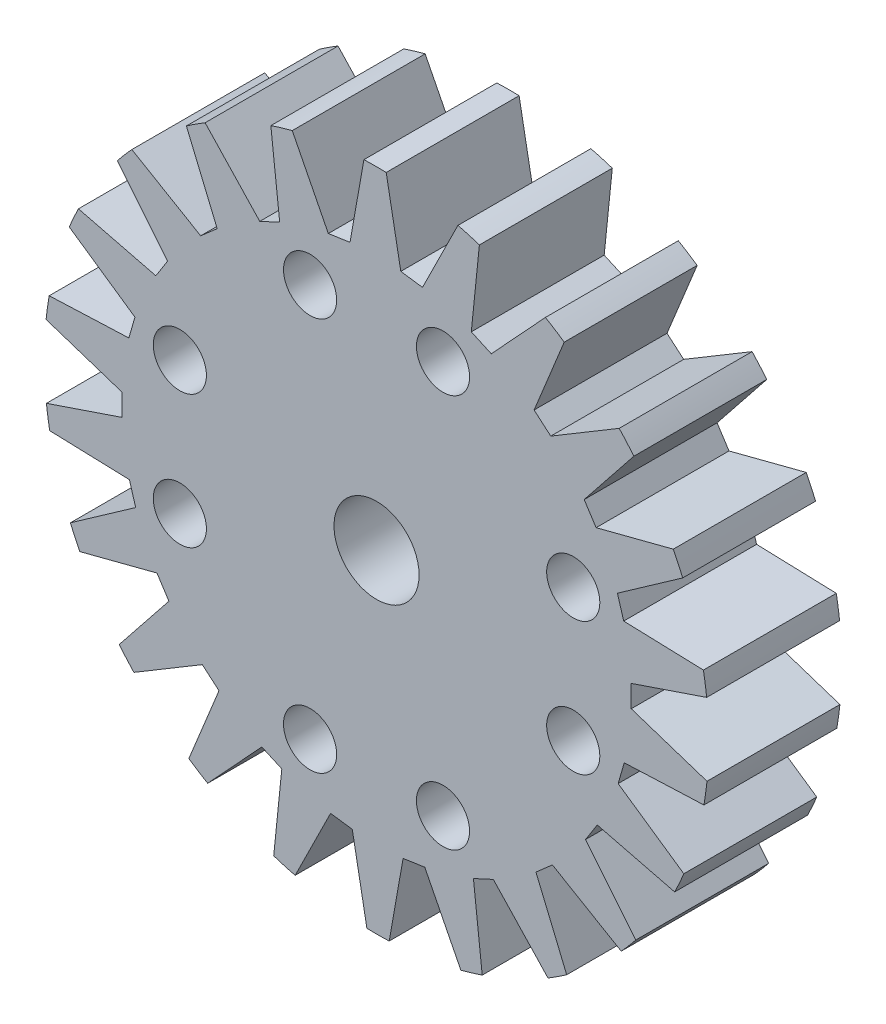
from build123d import *

# Parameters (mm, degrees)
SKETCH1_R           = 12.5
SKETCH1_R_2         = 1.6
SKETCH1_R_3         = 1
BOSS_EXTRUDE1_DEPTH = 5
CUT_EXTRUDE1_DEPTH  = 6
CIRPATTERN1_COUNT   = 22


with BuildPart() as part:
    # Sketch1 → Boss-Extrude1 (new body)
    with BuildSketch(Plane.XY):
        Circle(SKETCH1_R)
        Circle(SKETCH1_R_2, mode=Mode.SUBTRACT)
        with Locations((-2.5, 7.4)):
            Circle(SKETCH1_R_3, mode=Mode.SUBTRACT)
        with Locations((2.5, 7.4)):
            Circle(SKETCH1_R_3, mode=Mode.SUBTRACT)
        with Locations((2.5, -7.4)):
            Circle(SKETCH1_R_3, mode=Mode.SUBTRACT)
        with Locations((-2.5, -7.4)):
            Circle(SKETCH1_R_3, mode=Mode.SUBTRACT)
        with Locations((7.4, -2.5)):
            Circle(SKETCH1_R_3, mode=Mode.SUBTRACT)
        with Locations((7.4, 2.5)):
            Circle(SKETCH1_R_3, mode=Mode.SUBTRACT)
        with Locations((-7.4, 2.5)):
            Circle(SKETCH1_R_3, mode=Mode.SUBTRACT)
        with Locations((-7.4, -2.5)):
            Circle(SKETCH1_R_3, mode=Mode.SUBTRACT)
    extrude(amount=BOSS_EXTRUDE1_DEPTH)

    # Sketch2 → Cut-Extrude1 (cut, through all)
    with BuildSketch(Plane.XY.offset(5)):
        Polygon((-9.204992805, 8.456837911), (-6.616673599, 6.940063806), (-5.995627184, 7.483135026), (-7.153657676, 10.250618608), (-7.456074993, 10.596457577), (-9.507410122, 8.80267688), align=None)
    cut_extrude1 = extrude(amount=-CUT_EXTRUDE1_DEPTH, mode=Mode.SUBTRACT)

    # CirPattern1: Cut-Extrude1 ×22 about axis
    cirpattern1_axis = Axis((0, 0, 0), (0, 0, 1))
    for i in range(1, CIRPATTERN1_COUNT):
        add(cut_extrude1.rotate(cirpattern1_axis, i * 360 / CIRPATTERN1_COUNT), mode=Mode.SUBTRACT)


solid = part.part
